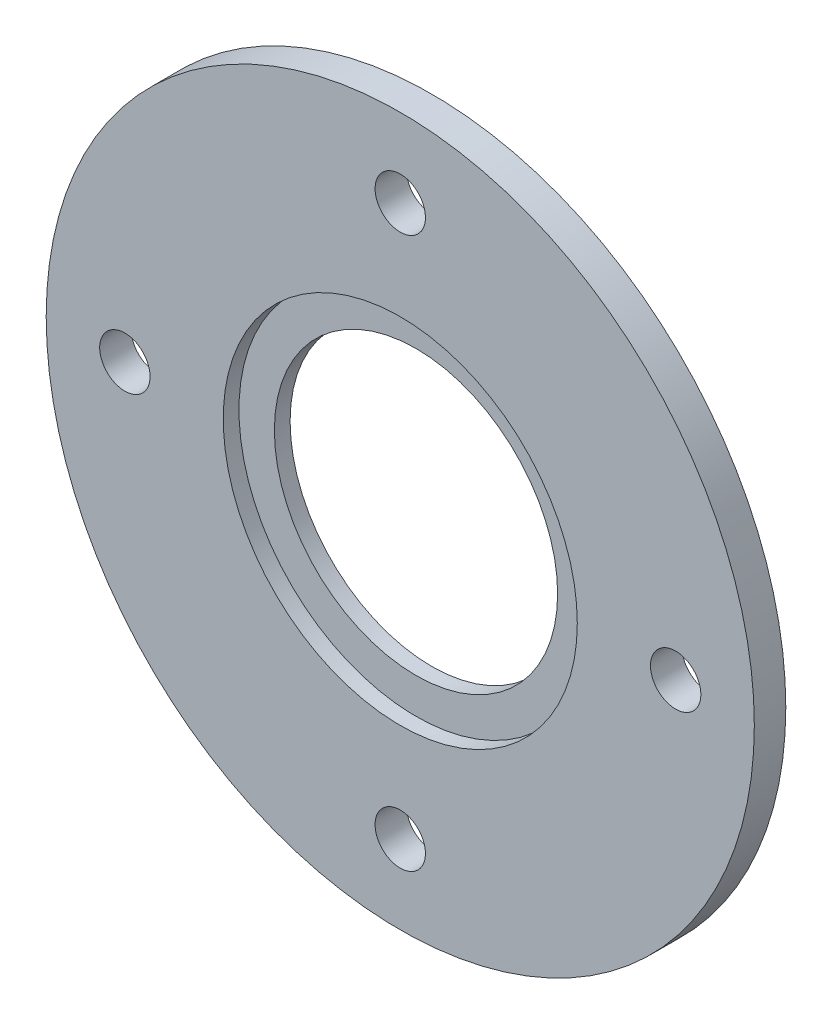
from build123d import *

# Parameters (mm, degrees)
SKETCH_1_R               = 22.5
SKETCH_1_R_2             = 9
EXTRUDE_1_DEPTH          = 2
SKETCH_2_R               = 1.6
CUT_EXTRUDE_1_DEPTH      = 3
PATTERN_CIRCULAR_2_COUNT = 4
SKETCH_3_R               = 11.25
SKETCH_3_R_2             = 9
CUT_EXTRUDE_2_DEPTH      = 1


with BuildPart() as part:
    # ｽｹｯﾁ1 → ﾎﾞｽ - 押し出し1 (new body)
    with BuildSketch(Plane.XY):
        Circle(SKETCH_1_R)
        Circle(SKETCH_1_R_2, mode=Mode.SUBTRACT)
    extrude(amount=EXTRUDE_1_DEPTH)

    # ｽｹｯﾁ2 → ｶｯﾄ - 押し出し1 (cut, through all)
    with BuildSketch(Plane.XY.offset(2)):
        with Locations((-17.5, 0)):
            Circle(SKETCH_2_R)
    cut_extrude_1 = extrude(amount=-CUT_EXTRUDE_1_DEPTH, mode=Mode.SUBTRACT)

    # 円形ﾊﾟﾀｰﾝ2: ｶｯﾄ - 押し出し1 ×4 about axis
    pattern_circular_2_axis = Axis((0, 0, 0), (0, 0, 1))
    for i in range(1, PATTERN_CIRCULAR_2_COUNT):
        add(cut_extrude_1.rotate(pattern_circular_2_axis, i * 360 / PATTERN_CIRCULAR_2_COUNT), mode=Mode.SUBTRACT)

    # ｽｹｯﾁ3 → ｶｯﾄ - 押し出し2 (cut)
    with BuildSketch(Plane.XY.offset(2)):
        Circle(SKETCH_3_R)
        Circle(SKETCH_3_R_2, mode=Mode.SUBTRACT)
    extrude(amount=-CUT_EXTRUDE_2_DEPTH, mode=Mode.SUBTRACT)


solid = part.part
